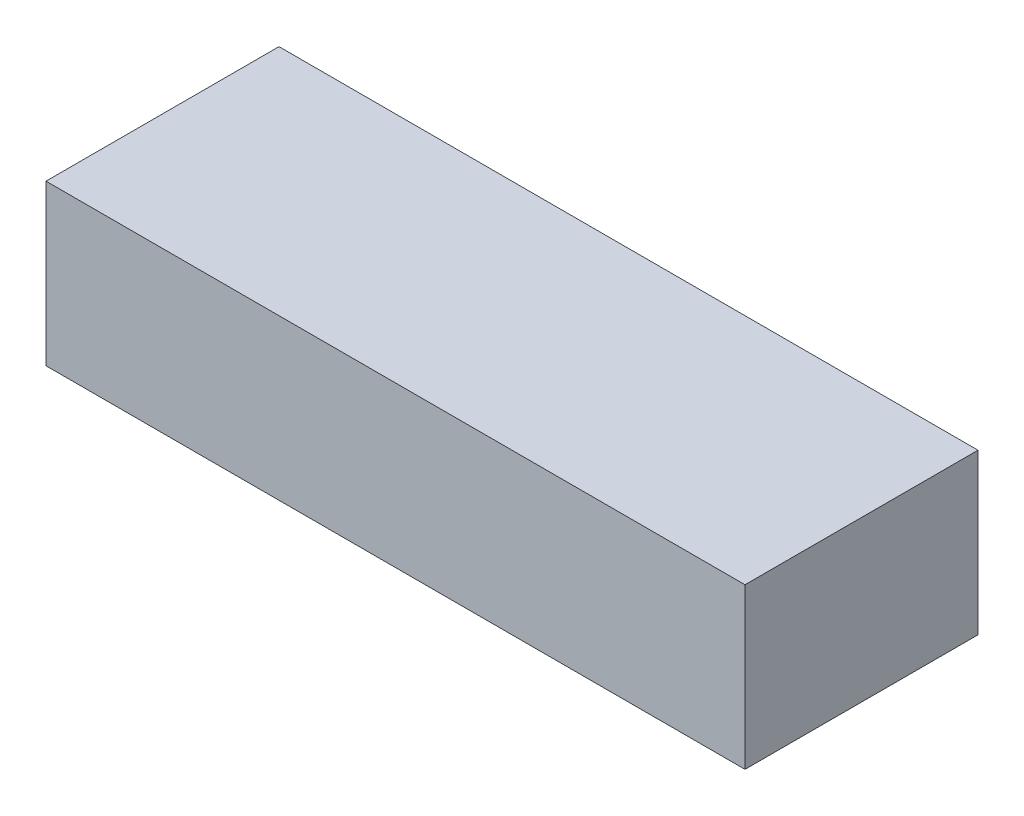
from build123d import *

# Parameters (mm, degrees)
SKETCH1_W           = 306
SKETCH1_H           = 102
BOSS_EXTRUDE1_DEPTH = 70


with BuildPart() as part:
    # Sketch1 → Boss-Extrude1 (new body)
    with BuildSketch(Plane(origin=(0, 0, 0), x_dir=(1, 0, 0), z_dir=(0, 1, 0))):
        Rectangle(SKETCH1_W, SKETCH1_H)
    extrude(amount=BOSS_EXTRUDE1_DEPTH)


solid = part.part
